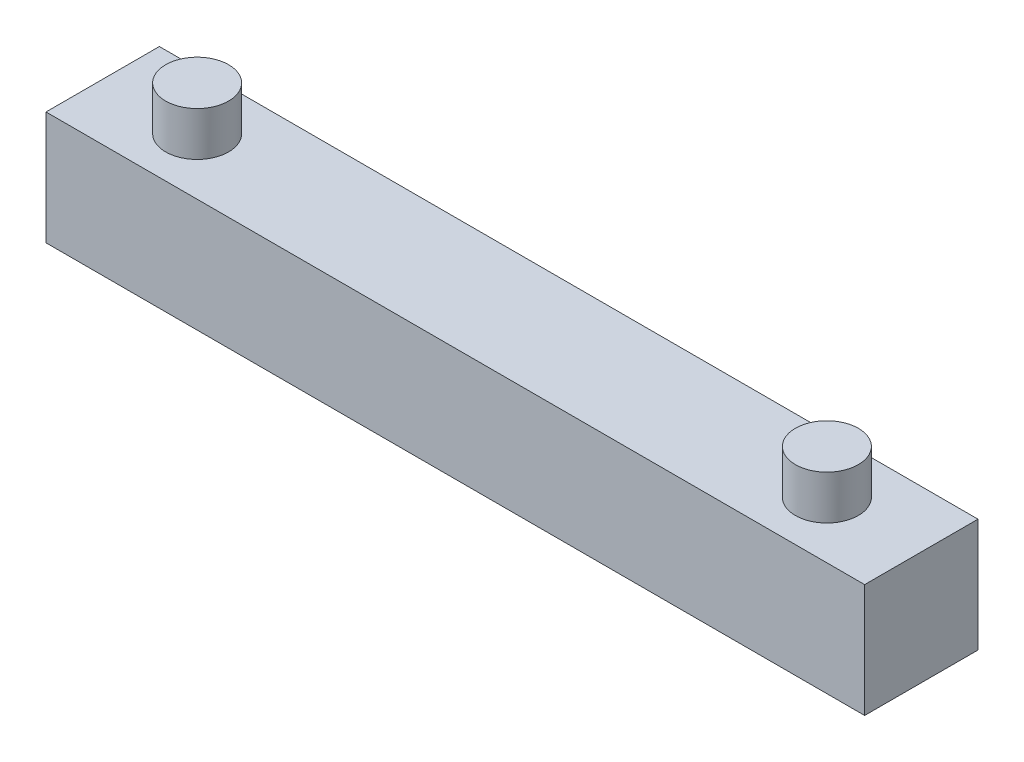
from build123d import *

# Parameters (mm, degrees)
SKETCH1_W           = 65
SKETCH1_H           = 9
BOSS_EXTRUDE1_DEPTH = 9
SKETCH2_R           = 2.5
BOSS_EXTRUDE3_DEPTH = 3.5


with BuildPart() as part:
    # Sketch1 → Boss-Extrude1 (new body)
    with BuildSketch(Plane.XY):
        with Locations((32.5, 4.5)):
            Rectangle(SKETCH1_W, SKETCH1_H)
    extrude(amount=BOSS_EXTRUDE1_DEPTH)

    # Sketch2 → Boss-Extrude3 (add)
    with BuildSketch(Plane(origin=(0, 9, 0), x_dir=(1, 0, 0), z_dir=(0, 1, 0))):
        with Locations(Location((7.5, -4.5, 0), (0, 0, 90))):  # turned: the seam where the file's is
            Circle(SKETCH2_R)
        with Locations(Location((57.5, -4.5, 0), (0, 0, 90))):  # turned: the seam where the file's is
            Circle(SKETCH2_R)
    extrude(amount=BOSS_EXTRUDE3_DEPTH)


solid = part.part
